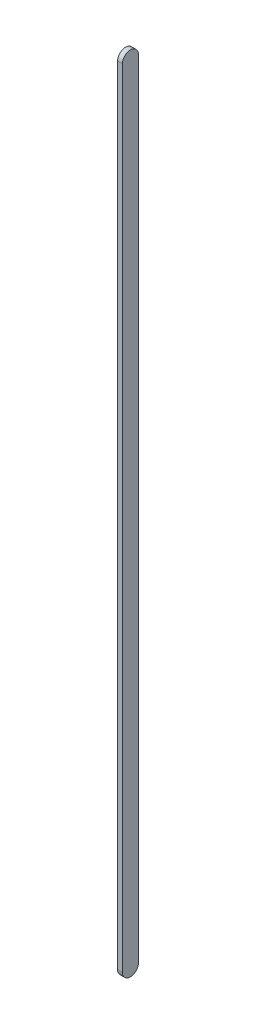
from build123d import *

# Parameters (mm, degrees)
BOSS_EXTRUDE1_DEPTH = 3


with BuildPart() as part:
    # Sketch1 → Boss-Extrude1 (new body)
    with BuildSketch(Plane(origin=(0, 0, 0), x_dir=(0, 0, -1), z_dir=(1, 0, 0))):
        with BuildLine():
            Line((-5, -490), (-5, 0))
            ThreePointArc((-5, 0), (0, 5), (5, 0))
            Line((5, 0), (5, -490))
            ThreePointArc((5, -490), (0, -495), (-5, -490))
        make_face()
    extrude(amount=BOSS_EXTRUDE1_DEPTH)


solid = part.part
